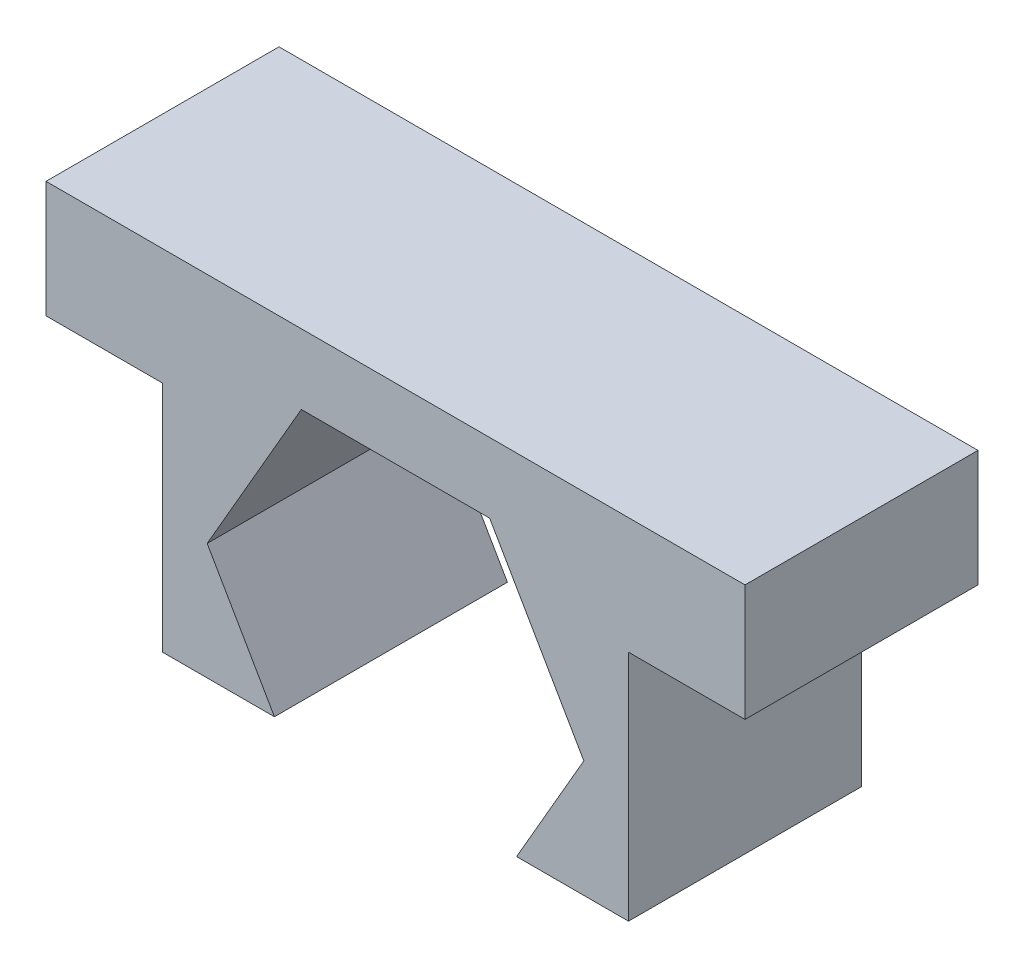
from build123d import *

# Parameters (mm, degrees)
BOSS_EXTRUDE1_DEPTH = 5


with BuildPart() as part:
    # Sketch1 → Boss-Extrude1 (new body)
    with BuildSketch(Plane.XY):
        Polygon((0, 7.5), (0, 2.5), (2.401923789, 2.5), (0.958548116, 5), (2.979274058, 8.5), (7.020725942, 8.5), (9.041451884, 5), (7.598076211, 2.5), (10, 2.5), (10, 7.5), (12.5, 7.5), (12.5, 10), (-2.5, 10), (-2.5, 7.5), align=None)
    extrude(amount=BOSS_EXTRUDE1_DEPTH)


solid = part.part
